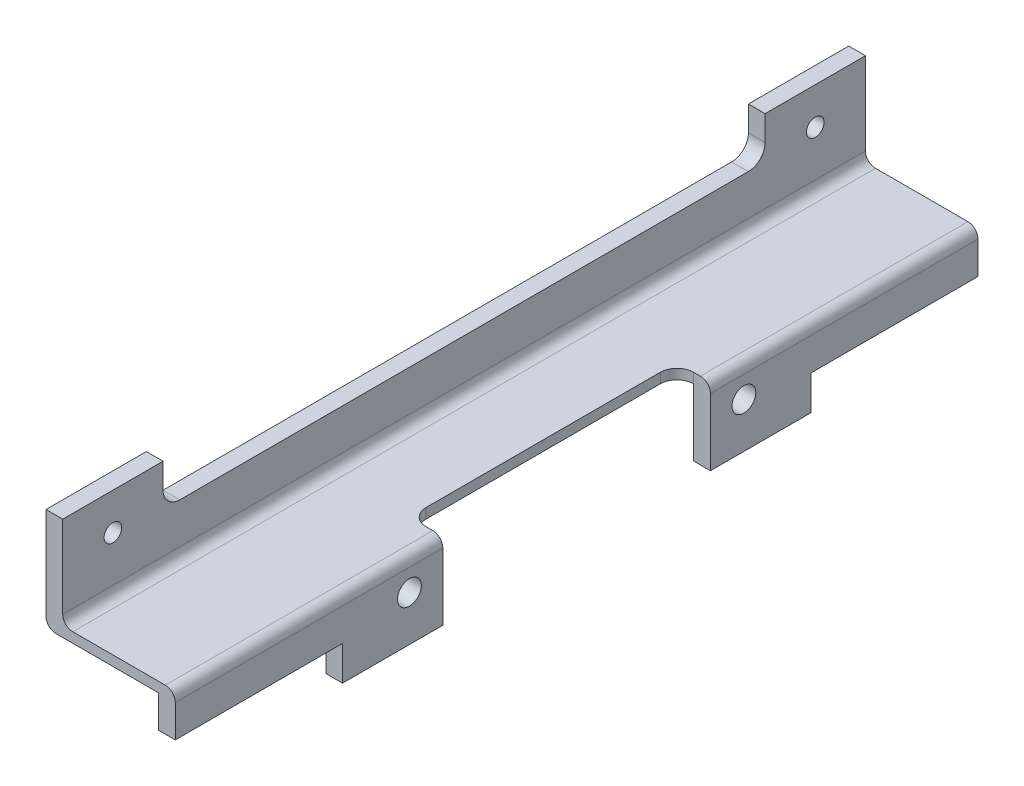
from build123d import *

# Parameters (mm, degrees)
EXTRUDE_THIN1_DEPTH                       = 240
FILLET1_R                                 = 3
SKETCH3_W                                 = 35
SKETCH3_H                                 = 300
EXTRUDE2_DEPTH                            = 7.35
SKETCH7_W                                 = 300
SKETCH7_H                                 = 40
EXTRUDE4_DEPTH                            = 7.35
EXTRUDE5_DEPTH                            = 7.35
TAPPED_HOLE_FOR_8_32_HELICOIL_D           = 4.3942
TAPPED_HOLE_FOR_8_32_HELICOIL_CBORE_D     = 5.27558
TAPPED_HOLE_FOR_8_32_HELICOIL_CBORE_DEPTH = 5.08
SKETCH20_W                                = 240
SKETCH20_H                                = 34
EXTRUDE12_DEPTH                           = 1.35
SKETCH21_W                                = 30.65
SKETCH21_H                                = 240
EXTRUDE13_DEPTH                           = 3.35
SKETCH22_W                                = 240
SKETCH22_H                                = 3
EXTRUDE14_DEPTH                           = 3
SKETCH23_W                                = 5
SKETCH23_H                                = 23
EXTRUDE15_DEPTH                           = 240
SKETCH24_R                                = 3.5687
EXTRUDE16_DEPTH                           = 39.65
SKETCH25_W                                = 80
SKETCH25_H                                = 60.65
EXTRUDE17_DEPTH                           = 10
FILLET4_R                                 = 5
SKETCH31_W                                = 50
SKETCH31_H                                = 10.3
EXTRUDE23_DEPTH                           = 41
FILLET5_R                                 = 3


with BuildPart() as part:
    # Sketch1 → Extrude-Thin1 (new body)
    with BuildSketch(Plane.XY):
        Polygon((0, 50.8), (0, 0), (50.8, 0), (50.8, 6.35), (6.35, 6.35), (6.35, 50.8), align=None)
    extrude(amount=-EXTRUDE_THIN1_DEPTH)

    # Fillet1
    fillet1_edges = [part.edges().sort_by_distance(p)[0] for p in [
        (6.35, 6.35, -120),
        (50.8, 6.35, -120),
        (6.35, 50.8, -120),
    ]]
    fillet(fillet1_edges, radius=FILLET1_R)

    # Sketch3 → Extrude2 (cut, through all)
    with BuildSketch(Plane(origin=(0, 6.35, 0), x_dir=(1, 0, 0), z_dir=(0, 1, 0))):
        with Locations((49.5, 95)):
            Rectangle(SKETCH3_W, SKETCH3_H)
    extrude(amount=-EXTRUDE2_DEPTH, mode=Mode.SUBTRACT)

    # Sketch7 → Extrude4 (cut, through all)
    with BuildSketch(Plane(origin=(6.35, 0, 0), x_dir=(0, 0, -1), z_dir=(1, 0, 0))):
        with Locations((145, 54)):
            Rectangle(SKETCH7_W, SKETCH7_H)
    extrude(amount=-EXTRUDE4_DEPTH, mode=Mode.SUBTRACT)

    # Sketch10 → Extrude5 (cut, through all)
    with BuildSketch(Plane(origin=(6.35, 0, 0), x_dir=(0, 0, -1), z_dir=(1, 0, 0))):
        with BuildLine():
            Line((30, 51.5), (210, 51.5))
            Line((210, 51.5), (210, 26.5))
            ThreePointArc((210, 26.5), (208.535533906, 22.964466094), (205, 21.5))
            Line((205, 21.5), (35, 21.5))
            ThreePointArc((35, 21.5), (31.464466094, 22.964466094), (30, 26.5))
            Line((30, 26.5), (30, 51.5))
        make_face()
    extrude(amount=-EXTRUDE5_DEPTH, mode=Mode.SUBTRACT)

    # Tapped Hole for #8-32 Helicoil (through all)
    with Locations(Plane(origin=(6.35, 23, -15), x_dir=(0, 0, 1), z_dir=(1, 0, 0))):
        with Locations((0, 0), (-210, 0)):
            CounterBoreHole(TAPPED_HOLE_FOR_8_32_HELICOIL_D / 2, TAPPED_HOLE_FOR_8_32_HELICOIL_CBORE_D / 2, TAPPED_HOLE_FOR_8_32_HELICOIL_CBORE_DEPTH)

    # Sketch20 → Extrude12 (cut)
    with BuildSketch(Plane.ZY):
        with Locations((-120, 17)):
            Rectangle(SKETCH20_W, SKETCH20_H)
    extrude(amount=-EXTRUDE12_DEPTH, mode=Mode.SUBTRACT)

    # Sketch21 → Extrude13 (cut)
    with BuildSketch(Plane.XZ):
        with Locations((16.675, -120)):
            Rectangle(SKETCH21_W, SKETCH21_H)
    extrude(amount=-EXTRUDE13_DEPTH, mode=Mode.SUBTRACT)

    # Sketch22 → Extrude14 (add)
    with BuildSketch(Plane(origin=(32, 0, 0), x_dir=(0, 0, -1), z_dir=(1, 0, 0))):
        with Locations((120, 4.85)):
            Rectangle(SKETCH22_W, SKETCH22_H)
    extrude(amount=EXTRUDE14_DEPTH)

    # Sketch23 → Extrude15 (add)
    with BuildSketch(Plane.XY):
        with Locations((37.5, -5.15)):
            Rectangle(SKETCH23_W, SKETCH23_H)
    extrude(amount=-EXTRUDE15_DEPTH)

    # Sketch24 → Extrude16 (cut, through all)
    with BuildSketch(Plane(origin=(40, 0, 0), x_dir=(0, 0, -1), z_dir=(1, 0, 0))):
        with Locations((170, -3.15)):
            Circle(SKETCH24_R)
        with Locations((70, -3.15)):
            Circle(SKETCH24_R)
    extrude(amount=-EXTRUDE16_DEPTH, mode=Mode.SUBTRACT)

    # Sketch25 → Extrude17 (cut)
    with BuildSketch(Plane(origin=(40, 0, 0), x_dir=(0, 0, -1), z_dir=(1, 0, 0))):
        with Locations((120, 3.675)):
            Rectangle(SKETCH25_W, SKETCH25_H)
    extrude(amount=-EXTRUDE17_DEPTH, mode=Mode.SUBTRACT)

    # Fillet4
    fillet4_edges = [part.edges().sort_by_distance(p)[0] for p in [
        (30, 4.85, -160),
        (30, 4.85, -80),
    ]]
    fillet(fillet4_edges, radius=FILLET4_R)

    # Sketch31 → Extrude23 (cut, through all)
    with BuildSketch(Plane(origin=(0, 0, 0), x_dir=(0, 0, -1), z_dir=(1, 0, 0))):
        with Locations((25, -11.5)):
            Rectangle(SKETCH31_W, SKETCH31_H)
        with Locations((215, -11.5)):
            Rectangle(SKETCH31_W, SKETCH31_H)
    extrude(amount=EXTRUDE23_DEPTH, mode=Mode.SUBTRACT)

    # Fillet5
    fillet5_edges = [part.edges().sort_by_distance(p)[0] for p in [
        (40, 6.35, -200),
        (40, 6.35, -40),
        (1.35, 3.35, -120),
    ]]
    fillet(fillet5_edges, radius=FILLET5_R)


solid = part.part
